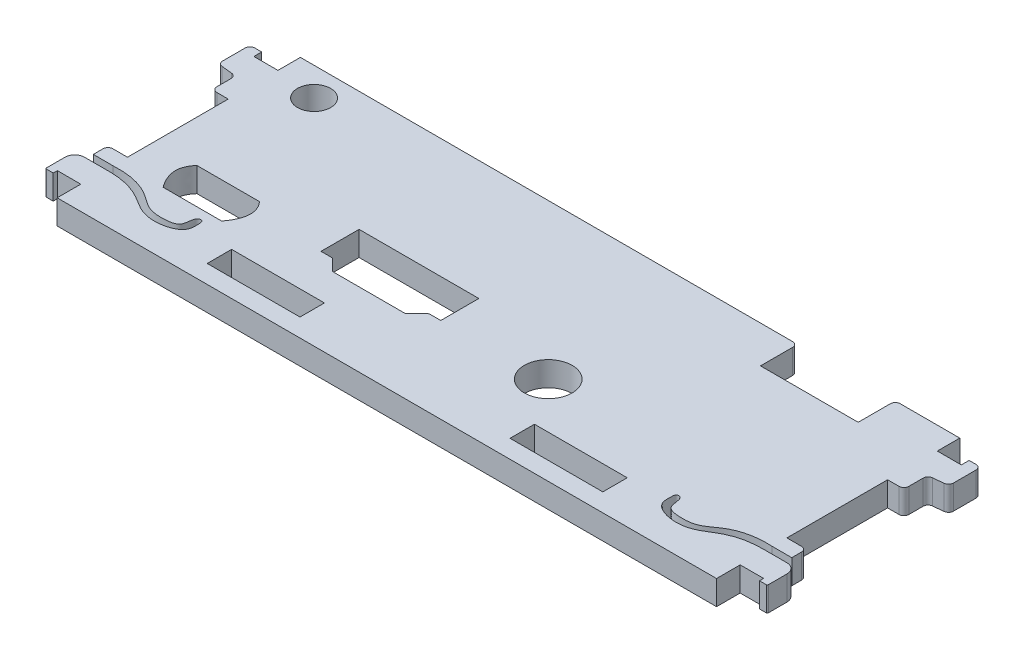
from build123d import *

# Parameters (mm, degrees)
SKETCH1_R           = 2.159
SKETCH1_R_2         = 3.1115
SKETCH1_W           = 12.065
SKETCH1_H           = 3.175
BOSS_EXTRUDE1_DEPTH = 3.175


with BuildPart() as part:
    # Sketch1 → Boss-Extrude1 (new body)
    with BuildSketch(Plane(origin=(0, 0, 0), x_dir=(1, 0, 0), z_dir=(0, 1, 0))):
        with BuildLine():
            Line((34.4805, 15.1765), (34.4805, 10.9855))
            Line((34.4805, 10.9855), (21.7805, 10.9855))
            Line((21.7805, 10.9855), (21.7805, 15.1765))
            ThreePointArc((21.7805, 15.1765), (21.594512806, 15.625512806), (21.1455, 15.8115))
            Line((21.1455, 15.8115), (-42.8625, 15.8115))
            Line((-42.8625, 15.8115), (-42.8625, 12.8905))
            Line((-42.8625, 12.8905), (-45.9867, 12.8905))
            Line((-45.9867, 12.8905), (-45.9867, 13.9065))
            Line((-45.9867, 13.9065), (-46.8757, 13.9065))
            ThreePointArc((-46.8757, 13.9065), (-47.324712806, 13.720512806), (-47.5107, 13.2715))
            Line((-47.5107, 13.2715), (-47.5107, 10.338056568))
            ThreePointArc((-47.5107, 10.338056568), (-47.347596964, 9.913158633), (-46.942075574, 9.706535165))
            Line((-46.942075574, 9.706535165), (-45.553238812, 9.560562539))
            ThreePointArc((-45.553238812, 9.560562539), (-45.147717422, 9.35393907), (-44.984614386, 8.929041135))
            Line((-44.984614386, 8.929041135), (-44.984614386, 7.062397703))
            ThreePointArc((-44.984614386, 7.062397703), (-44.798627192, 6.613384897), (-44.349614386, 6.427397703))
            Line((-44.349614386, 6.427397703), (-42.8625, 6.427397703))
            Line((-42.8625, 6.427397703), (-42.8625, -6.6675))
            Line((-42.8625, -6.6675), (-44.7675, -6.6675))
            ThreePointArc((-44.7675, -6.6675), (-45.216512806, -6.853487194), (-45.4025, -7.3025))
            Line((-45.4025, -7.3025), (-45.4025, -8.5725))
            Line((-45.4025, -8.5725), (-42.8625, -8.5725))
            add(Edge.make_bspline(
                [(-42.8625, -8.5725), (-41.005115551, -8.466473625), (-38.396028509, -8.887813668), (-35.813813666, -11.145112068), (-33.839391095, -11.353018381), (-31.687232336, -11.094331604), (-31.679651614, -9.758824593), (-31.429319526, -8.952680122), (-30.744472831, -8.892392446), (-30.681556581, -9.870798346), (-30.713644348, -11.451652587), (-33.525275685, -12.377060787), (-36.093380331, -11.829060286), (-38.792678311, -9.826426979), (-41.261119489, -9.41228692), (-42.8625, -9.4615)],
                knots=[0, 0, 0, 0, 0.193261579, 0.266307353, 0.344937089, 0.408050915, 0.447196341, 0.474222778, 0.483836988, 0.508634301, 0.551486029, 0.654565368, 0.748054069, 0.830603677, 1, 1, 1, 1], degree=3))
            Line((-42.8625, -9.4615), (-45.4025, -9.4615))
            Line((-45.4025, -9.4615), (-45.6565, -9.4615))
            ThreePointArc((-45.6565, -9.4615), (-46.554525612, -9.833474388), (-46.9265, -10.7315))
            Line((-46.9265, -10.7315), (-46.9265, -13.1445))
            ThreePointArc((-46.9265, -13.1445), (-46.889302561, -13.234302561), (-46.7995, -13.2715))
            Line((-46.7995, -13.2715), (-45.9105, -13.2715))
            Line((-45.9105, -13.2715), (-45.9105, -12.7381))
            Line((-45.9105, -12.7381), (-42.8625, -12.7381))
            Line((-42.8625, -12.7381), (-42.8625, -15.8115))
            Line((-42.8625, -15.8115), (42.8625, -15.8115))
            Line((42.8625, -15.8115), (42.8625, -12.7381))
            Line((42.8625, -12.7381), (45.9105, -12.7381))
            Line((45.9105, -12.7381), (45.9105, -13.2715))
            Line((45.9105, -13.2715), (46.7995, -13.2715))
            ThreePointArc((46.7995, -13.2715), (46.889302561, -13.234302561), (46.9265, -13.1445))
            Line((46.9265, -13.1445), (46.9265, -10.7315))
            ThreePointArc((46.9265, -10.7315), (46.554525612, -9.833474388), (45.6565, -9.4615))
            Line((45.6565, -9.4615), (45.4025, -9.4615))
            Line((45.4025, -9.4615), (42.8625, -9.4615))
            add(Edge.make_bspline(
                [(42.8625, -8.5725), (41.005115551, -8.466473625), (38.396028509, -8.887813668), (35.813813666, -11.145112068), (33.839391095, -11.353018381), (31.687232336, -11.094331604), (31.679651614, -9.758824593), (31.429319526, -8.952680122), (30.744472831, -8.892392446), (30.681556581, -9.870798346), (30.713644348, -11.451652587), (33.525275685, -12.377060787), (36.093380331, -11.829060286), (38.792678311, -9.826426979), (41.261119489, -9.41228692), (42.8625, -9.4615)],
                knots=[0, 0, 0, 0, 0.193261579, 0.266307353, 0.344937089, 0.408050915, 0.447196341, 0.474222778, 0.483836988, 0.508634301, 0.551486029, 0.654565368, 0.748054069, 0.830603677, 1, 1, 1, 1], degree=3))
            Line((42.8625, -8.5725), (45.4025, -8.5725))
            Line((45.4025, -8.5725), (45.4025, -7.3025))
            ThreePointArc((45.4025, -7.3025), (45.216512806, -6.853487194), (44.7675, -6.6675))
            Line((44.7675, -6.6675), (42.8625, -6.6675))
            Line((42.8625, -6.6675), (42.8625, 6.427397703))
            Line((42.8625, 6.427397703), (44.349614386, 6.427397703))
            ThreePointArc((44.349614386, 6.427397703), (44.798627192, 6.613384897), (44.984614386, 7.062397703))
            Line((44.984614386, 7.062397703), (44.984614386, 8.929041135))
            ThreePointArc((44.984614386, 8.929041135), (45.147717422, 9.35393907), (45.553238812, 9.560562539))
            Line((45.553238812, 9.560562539), (46.942075574, 9.706535165))
            ThreePointArc((46.942075574, 9.706535165), (47.347596964, 9.913158633), (47.5107, 10.338056568))
            Line((47.5107, 10.338056568), (47.5107, 13.2715))
            ThreePointArc((47.5107, 13.2715), (47.324712806, 13.720512806), (46.8757, 13.9065))
            Line((46.8757, 13.9065), (45.9867, 13.9065))
            Line((45.9867, 13.9065), (45.9867, 12.8905))
            Line((45.9867, 12.8905), (42.8625, 12.8905))
            Line((42.8625, 12.8905), (42.8625, 15.8115))
            Line((42.8625, 15.8115), (35.1155, 15.8115))
            ThreePointArc((35.1155, 15.8115), (34.666487194, 15.625512806), (34.4805, 15.1765))
        make_face()
        with Locations((-37.4015, 12.1285)):
            Circle(SKETCH1_R, mode=Mode.SUBTRACT)
        with Locations((9.4742, -4.3053)):
            Circle(SKETCH1_R_2, mode=Mode.SUBTRACT)
        with Locations((19.685, -11.8618)):
            Rectangle(SKETCH1_W, SKETCH1_H, mode=Mode.SUBTRACT)
        with Locations((-19.685, -11.8618)):
            Rectangle(SKETCH1_W, SKETCH1_H, mode=Mode.SUBTRACT)
        with BuildLine():
            Line((-19.685, 0.2667), (-4.1148, 0.2667))
            Line((-4.1148, 0.2667), (-4.1148, -4.6863))
            Line((-4.1148, -4.6863), (-5.533589755, -4.6863))
            ThreePointArc((-5.533589755, -4.6863), (-5.630791347, -4.705634599), (-5.713194878, -4.760694878))
            Line((-5.713194878, -4.760694878), (-7.1628, -6.2103))
            Line((-7.1628, -6.2103), (-16.637, -6.2103))
            Line((-16.637, -6.2103), (-18.086605122, -4.760694878))
            ThreePointArc((-18.086605122, -4.760694878), (-18.169008653, -4.705634599), (-18.266210245, -4.6863))
            Line((-18.266210245, -4.6863), (-19.685, -4.6863))
            Line((-19.685, -4.6863), (-19.685, 0.2667))
        make_face(mode=Mode.SUBTRACT)
        with BuildLine():
            Line((-37.4142, -3.085455207), (-29.2862, -3.085455207))
            add(Edge.make_bspline(
                [(-29.2862, -3.085455207), (-27.521624407, -5.014397473), (-29.5402, -7.733655207)],
                knots=[0, 0, 0, 1, 1, 1], degree=2))
            Line((-29.5402, -7.733655207), (-37.1602, -7.733655207))
            add(Edge.make_bspline(
                [(-37.4142, -3.085455207), (-39.178775593, -5.014397473), (-37.1602, -7.733655207)],
                knots=[0, 0, 0, 1, 1, 1], degree=2))
        make_face(mode=Mode.SUBTRACT)
    extrude(amount=BOSS_EXTRUDE1_DEPTH)


solid = part.part
